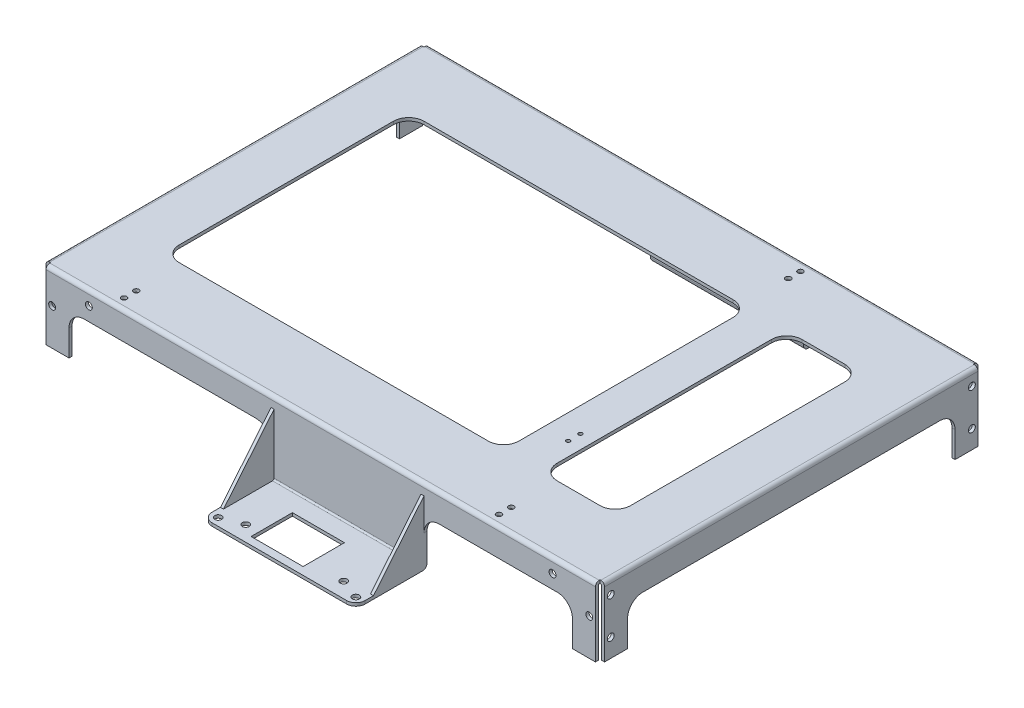
from build123d import *

# Parameters (mm, degrees)
BOSS_EXTRUDE1_DEPTH = 182.5
CUT_EXTRUDE1_DEPTH  = 251
BOSS_EXTRUDE2_START = 17.5
BOSS_EXTRUDE2_DEPTH = 50
BOSS_EXTRUDE3_DEPTH = 2
SKETCH5_R           = 11.25
SKETCH5_R_2         = 2.25
SKETCH5_W           = 34
SKETCH5_H           = 27
CUT_EXTRUDE2_DEPTH  = 2
FILLET1_R           = 10
SKETCH7_W           = 2
SKETCH7_H           = 246
BOSS_EXTRUDE4_DEPTH = 43
SKETCH8_W           = 3
SKETCH8_H           = 3
CUT_EXTRUDE4_DEPTH  = 46
FILLET2_R           = 0.5
FILLET3_R           = 2.5
CUT_EXTRUDE5_DEPTH  = 366
SKETCH10_R          = 2.25
CUT_EXTRUDE6_DEPTH  = 295.5
SKETCH11_R          = 2.25
CUT_EXTRUDE7_DEPTH  = 366
CUT_EXTRUDE8_DEPTH  = 3
SKETCH14_R          = 3.5
SKETCH14_R_2        = 8
CUT_EXTRUDE9_DEPTH  = 10
FILLET4_R           = 6
SKETCH15_R          = 1.75
SKETCH15_R_2        = 1.25
CUT_EXTRUDE10_DEPTH = 10


with BuildPart() as part:
    # Sketch1 → Boss-Extrude1 (new body, symmetric)
    with BuildSketch(Plane(origin=(0, 0, 0), x_dir=(0, 0, -1), z_dir=(1, 0, 0))):
        with BuildLine():
            Line((123, -45), (125, -45))
            Line((125, -45), (125, -2.5))
            ThreePointArc((125, -2.5), (124.267766953, -0.732233047), (122.5, 0))
            Line((122.5, 0), (-122.5, 0))
            ThreePointArc((-122.5, 0), (-124.267766953, -0.732233047), (-125, -2.5))
            Line((-125, -2.5), (-125, -45))
            Line((-125, -45), (-123, -45))
            Line((-123, -45), (-123, -2.5))
            ThreePointArc((-123, -2.5), (-122.853553391, -2.146446609), (-122.5, -2))
            Line((-122.5, -2), (122.5, -2))
            ThreePointArc((122.5, -2), (122.853553391, -2.146446609), (123, -2.5))
            Line((123, -2.5), (123, -45))
        make_face()
    extrude(amount=BOSS_EXTRUDE1_DEPTH, both=True)

    # Sketch2 → Cut-Extrude1 (cut, through all)
    with BuildSketch(Plane(origin=(0, 0, -125), x_dir=(-1, 0, 0), z_dir=(0, 0, -1))):
        with BuildLine():
            Line((-164.5, -45), (164.5, -45))
            Line((164.5, -45), (164.5, -28))
            ThreePointArc((164.5, -28), (161.571067812, -20.928932188), (154.5, -18))
            Line((154.5, -18), (-154.5, -18))
            ThreePointArc((-154.5, -18), (-161.571067812, -20.928932188), (-164.5, -28))
            Line((-164.5, -28), (-164.5, -45))
        make_face()
    extrude(amount=-CUT_EXTRUDE1_DEPTH, mode=Mode.SUBTRACT)

    # Sketch3 → Boss-Extrude2 (add, symmetric)
    with BuildSketch(Plane(origin=(0, 0, 0), x_dir=(0, 0, -1), z_dir=(1, 0, 0)).offset(BOSS_EXTRUDE2_START)):
        with BuildLine():
            Line((-169.5, -47), (-126, -47))
            ThreePointArc((-126, -47), (-125.292893219, -46.707106781), (-125, -46))
            Line((-125, -46), (-125, -18))
            Line((-125, -18), (-123, -18))
            Line((-123, -18), (-123, -46))
            ThreePointArc((-123, -46), (-123.878679656, -48.121320344), (-126, -49))
            Line((-126, -49), (-169.5, -49))
            Line((-169.5, -49), (-169.5, -47))
        make_face()
        with BuildLine():
            Line((126, -47), (169.5, -47))
            Line((169.5, -47), (169.5, -49))
            Line((169.5, -49), (126, -49))
            ThreePointArc((126, -49), (123.878679656, -48.121320344), (123, -46))
            Line((123, -46), (123, -18))
            Line((123, -18), (125, -18))
            Line((125, -18), (125, -46))
            ThreePointArc((125, -46), (125.292893219, -46.707106781), (126, -47))
        make_face()
    extrude(amount=BOSS_EXTRUDE2_DEPTH, both=True)

    # Sketch4 → Boss-Extrude3 (add)
    with BuildSketch(Plane.ZY.offset(32.5)):
        Polygon((125, -7), (158, -47), (125, -47), align=None)
        Polygon((-125, -7), (-158, -47), (-125, -47), align=None)
    boss_extrude3 = extrude(amount=-BOSS_EXTRUDE3_DEPTH)

    # Mirror1: Boss-Extrude3 across plane
    add(boss_extrude3.mirror(Plane(origin=(17.5, 0, 0), x_dir=(0, 0, 1), z_dir=(1, 0, 0))))

    # Sketch5 → Cut-Extrude2 (cut)
    with BuildSketch(Plane.XZ.offset(49)):
        with Locations(Location((17.5, -148.5, 0), (0, 0, 270))):  # turned: the seam where the file's is
            Circle(SKETCH5_R)
        with Locations(Location((2, -133, 0), (0, 0, 270))):  # turned: the seam where the file's is
            Circle(SKETCH5_R_2)
        with Locations(Location((2, -164, 0), (0, 0, 270))):  # turned: the seam where the file's is
            Circle(SKETCH5_R_2)
        with Locations(Location((33, -164, 0), (0, 0, 270))):  # turned: the seam where the file's is
            Circle(SKETCH5_R_2)
        with Locations(Location((33, -133, 0), (0, 0, 270))):  # turned: the seam where the file's is
            Circle(SKETCH5_R_2)
        with Locations(Location((-27.5, -164.5, 0), (0, 0, 270))):  # turned: the seam where the file's is
            Circle(SKETCH5_R_2)
        with Locations(Location((-14.5, -141.85, 0), (0, 0, 270))):  # turned: the seam where the file's is
            Circle(SKETCH5_R_2)
        with Locations(Location((49.5, -141.85, 0), (0, 0, 270))):  # turned: the seam where the file's is
            Circle(SKETCH5_R_2)
        with Locations(Location((-27.5, 164.5, 0), (0, 0, 270))):  # turned: the seam where the file's is
            Circle(SKETCH5_R_2)
        with Locations(Location((-14.5, 159.5, 0), (0, 0, 270))):  # turned: the seam where the file's is
            Circle(SKETCH5_R_2)
        with Locations(Location((49.5, 159.5, 0), (0, 0, 270))):  # turned: the seam where the file's is
            Circle(SKETCH5_R_2)
        with Locations(Location((62.5, -164.5, 0), (0, 0, 270))):  # turned: the seam where the file's is
            Circle(SKETCH5_R_2)
        with Locations(Location((62.5, 164.5, 0), (0, 0, 270))):  # turned: the seam where the file's is
            Circle(SKETCH5_R_2)
        with Locations((11, 151)):
            Rectangle(SKETCH5_W, SKETCH5_H)
    extrude(amount=-CUT_EXTRUDE2_DEPTH, mode=Mode.SUBTRACT)

    # Fillet1
    fillet1_edges = [part.edges().sort_by_distance(p)[0] for p in [
        (-32.5, -18, 124),
        (67.5, -18, 124),
        (-32.5, -18, -124),
        (67.5, -18, -124),
    ]]
    fillet(fillet1_edges, radius=FILLET1_R)

    # Sketch7 → Boss-Extrude4 (add)
    with BuildSketch(Plane.XZ.offset(2)):
        with Locations((-181.5, 0)):
            Rectangle(SKETCH7_W, SKETCH7_H)
        with Locations((181.5, 0)):
            Rectangle(SKETCH7_W, SKETCH7_H)
    extrude(amount=BOSS_EXTRUDE4_DEPTH)

    # Sketch8 → Cut-Extrude4 (cut, through all)
    with BuildSketch(Plane.XZ.offset(45)):
        with Locations((-181, 123.5)):
            Rectangle(SKETCH8_W, SKETCH8_H)
        with Locations((-181, -123.5)):
            Rectangle(SKETCH8_W, SKETCH8_H)
        with Locations((181, -123.5)):
            Rectangle(SKETCH8_W, SKETCH8_H)
        with Locations((181, 123.5)):
            Rectangle(SKETCH8_W, SKETCH8_H)
    extrude(amount=-CUT_EXTRUDE4_DEPTH, mode=Mode.SUBTRACT)

    # Fillet2
    fillet2_edges = [part.edges().sort_by_distance(p)[0] for p in [
        (-180.5, -2, 0),
        (180.5, -2, 0),
    ]]
    fillet(fillet2_edges, radius=FILLET2_R)

    # Fillet3
    fillet3_edges = [part.edges().sort_by_distance(p)[0] for p in [
        (-182.5, 0, 0),
        (182.5, 0, 0),
    ]]
    fillet(fillet3_edges, radius=FILLET3_R)

    # Sketch9 → Cut-Extrude5 (cut, through all)
    with BuildSketch(Plane.ZY.offset(182.5)):
        with BuildLine():
            Line((-107, -45), (107, -45))
            Line((107, -45), (107, -28))
            ThreePointArc((107, -28), (104.071067812, -20.928932188), (97, -18))
            Line((97, -18), (-97, -18))
            ThreePointArc((-97, -18), (-104.071067812, -20.928932188), (-107, -28))
            Line((-107, -28), (-107, -45))
        make_face()
    extrude(amount=-CUT_EXTRUDE5_DEPTH, mode=Mode.SUBTRACT)

    # Sketch10 → Cut-Extrude6 (cut, through all)
    with BuildSketch(Plane.XY.offset(125)):
        with Locations((-175.5, -21)):
            Circle(SKETCH10_R)
        with Locations((-151.5, -9)):
            Circle(SKETCH10_R)
        with Locations((151.5, -9)):
            Circle(SKETCH10_R)
        with Locations((175.5, -21)):
            Circle(SKETCH10_R)
    extrude(amount=-CUT_EXTRUDE6_DEPTH, mode=Mode.SUBTRACT)

    # Sketch11 → Cut-Extrude7 (cut, through all)
    with BuildSketch(Plane.ZY.offset(182.5)):
        with Locations((-118, -9)):
            Circle(SKETCH11_R)
        with Locations((-118, -33)):
            Circle(SKETCH11_R)
        with Locations((118, -9)):
            Circle(SKETCH11_R)
        with Locations((118, -33)):
            Circle(SKETCH11_R)
    extrude(amount=-CUT_EXTRUDE7_DEPTH, mode=Mode.SUBTRACT)

    # Sketch12 → Cut-Extrude8 (cut, through all)
    with BuildSketch(Plane.XZ.offset(2)):
        with BuildLine():
            Line((109.5, 80), (137.5, 80))
            ThreePointArc((137.5, 80), (144.571067812, 77.071067812), (147.5, 70))
            Line((147.5, 70), (147.5, -70))
            ThreePointArc((147.5, -70), (144.571067812, -77.071067812), (137.5, -80))
            Line((137.5, -80), (109.5, -80))
            ThreePointArc((109.5, -80), (102.428932188, -77.071067812), (99.5, -70))
            Line((99.5, -70), (99.5, 70))
            ThreePointArc((99.5, 70), (102.428932188, 77.071067812), (109.5, 80))
        make_face()
        with BuildLine():
            Line((-137.5, 80), (64.5, 80))
            ThreePointArc((64.5, 80), (71.571067812, 77.071067812), (74.5, 70))
            Line((74.5, 70), (74.5, -70))
            ThreePointArc((74.5, -70), (71.571067812, -77.071067812), (64.5, -80))
            Line((64.5, -80), (-137.5, -80))
            ThreePointArc((-137.5, -80), (-144.571067812, -77.071067812), (-147.5, -70))
            Line((-147.5, -70), (-147.5, 70))
            ThreePointArc((-147.5, 70), (-144.571067812, 77.071067812), (-137.5, 80))
        make_face()
    extrude(amount=-CUT_EXTRUDE8_DEPTH, mode=Mode.SUBTRACT)

    # Sketch14 → Cut-Extrude9 (cut)
    with BuildSketch(Plane(origin=(0, 0, -125), x_dir=(-1, 0, 0), z_dir=(0, 0, -1))):
        with Locations((-112.5, -10)):
            Circle(SKETCH14_R)
        with Locations((112.5, -10)):
            Circle(SKETCH14_R)
        with Locations((-51.5, -11)):
            Circle(SKETCH14_R_2)
    extrude(amount=-CUT_EXTRUDE9_DEPTH, mode=Mode.SUBTRACT)

    # Fillet4
    fillet4_edges = [part.edges().sort_by_distance(p)[0] for p in [
        (-32.5, -48, 169.5),
        (67.5, -48, 169.5),
        (-32.5, -48, -169.5),
        (67.5, -48, -169.5),
    ]]
    fillet(fillet4_edges, radius=FILLET4_R)

    # Sketch15 → Cut-Extrude10 (cut)
    with BuildSketch(Plane(origin=(0, 0, 0), x_dir=(1, 0, 0), z_dir=(0, 1, 0))):
        with Locations(Location((109.5, -118, 0), (0, 0, 270))):  # turned: the seam where the file's is
            Circle(SKETCH15_R)
        with Locations(Location((109.5, -110, 0), (0, 0, 270))):  # turned: the seam where the file's is
            Circle(SKETCH15_R)
        with Locations(Location((-135.5, -118, 0), (0, 0, 270))):  # turned: the seam where the file's is
            Circle(SKETCH15_R)
        with Locations(Location((-135.5, -110, 0), (0, 0, 270))):  # turned: the seam where the file's is
            Circle(SKETCH15_R)
        with Locations(Location((70.5, 110, 0), (0, 0, 270))):  # turned: the seam where the file's is
            Circle(SKETCH15_R)
        with Locations(Location((70.5, 118, 0), (0, 0, 270))):  # turned: the seam where the file's is
            Circle(SKETCH15_R)
        with Locations(Location((90.5, -53.8, 0), (0, 0, 270))):  # turned: the seam where the file's is
            Circle(SKETCH15_R_2)
        with Locations(Location((90.5, -45.8, 0), (0, 0, 270))):  # turned: the seam where the file's is
            Circle(SKETCH15_R_2)
    extrude(amount=-CUT_EXTRUDE10_DEPTH, mode=Mode.SUBTRACT)


solid = part.part
